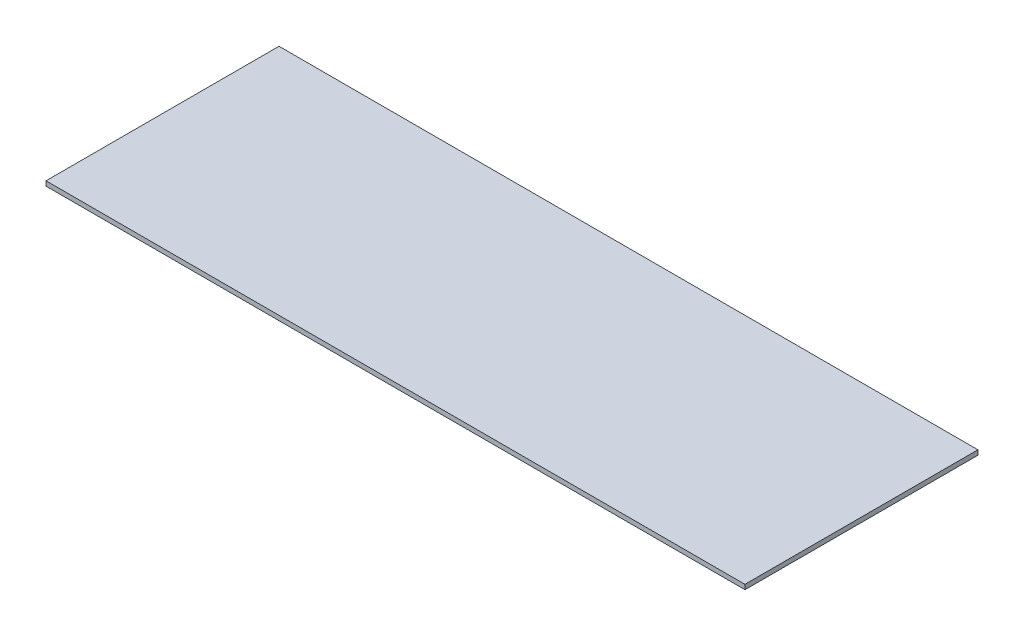
from build123d import *

# Parameters (mm, degrees)
SKETCH1_W           = 300
SKETCH1_H           = 100
BOSS_EXTRUDE1_DEPTH = 2
CUT_EXTRUDE1_DEPTH  = 101


with BuildPart() as part:
    # Sketch1 → Boss-Extrude1 (new body)
    with BuildSketch(Plane(origin=(0, 0, 0), x_dir=(1, 0, 0), z_dir=(0, 1, 0))):
        Rectangle(SKETCH1_W, SKETCH1_H)
    extrude(amount=BOSS_EXTRUDE1_DEPTH)

    # Sketch2 → Cut-Extrude1 (cut, through all)
    with BuildSketch(Plane.XY.offset(50)):
        Polygon((-150, 2), (-149.96508987, 0), (-150, 0), align=None)
        Polygon((150, 0), (149.96508987, 2), (150, 2), align=None)
    extrude(amount=-CUT_EXTRUDE1_DEPTH, mode=Mode.SUBTRACT)


solid = part.part
